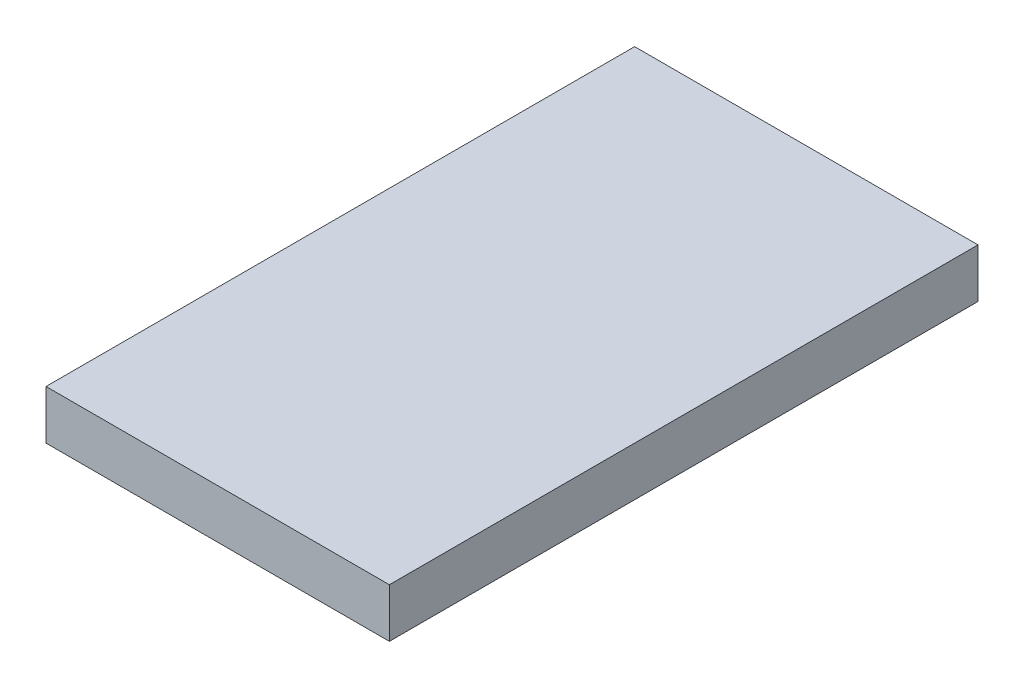
from build123d import *

# Parameters (mm, degrees)
ESBO_O1_W                = 700
ESBO_O1_H                = 100
RESSALTO_EXTRUS_O1_DEPTH = 1200


with BuildPart() as part:
    # Esboço1 → Ressalto-extrusão1 (new body)
    with BuildSketch(Plane.XY):
        with Locations((350, 50)):
            Rectangle(ESBO_O1_W, ESBO_O1_H)
    extrude(amount=RESSALTO_EXTRUS_O1_DEPTH)


solid = part.part
